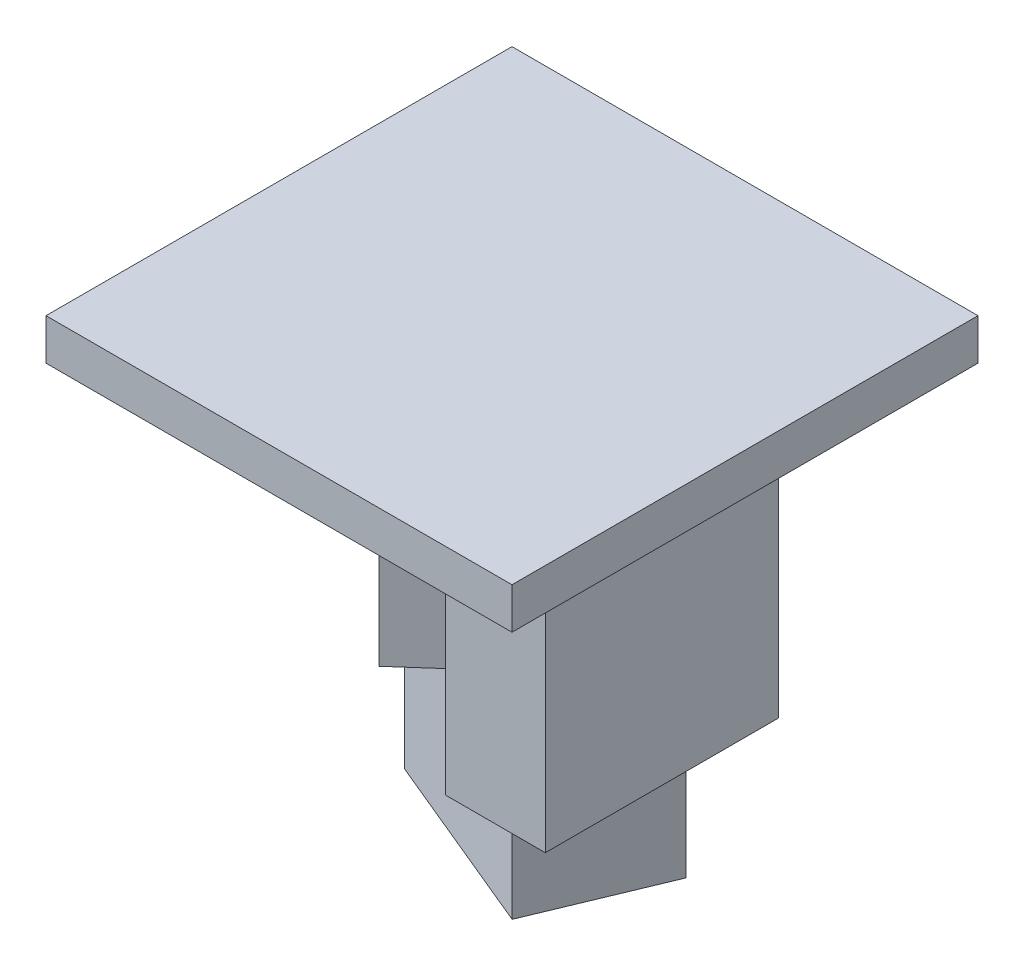
from build123d import *

# Parameters (mm, degrees)
SKETCH2_W           = 177.8
SKETCH2_H           = 177.8
BOSS_EXTRUDE2_DEPTH = 12.7
SKETCH2_2_W         = 177.8
SKETCH2_2_H         = 177.8
BOSS_EXTRUDE3_DEPTH = 3
SKETCH3_W           = 38.1
SKETCH3_H           = 88.9
BOSS_EXTRUDE4_DEPTH = 104.6
BOSS_EXTRUDE5_DEPTH = 53.8


with BuildPart() as part:
    # Sketch2 → Boss-Extrude2 (new body)
    with BuildSketch(Plane(origin=(0, 0, 0), x_dir=(1, 0, 0), z_dir=(0, 1, 0))):
        Rectangle(SKETCH2_W, SKETCH2_H)
    extrude(amount=BOSS_EXTRUDE2_DEPTH)

    # Sketch2_2 → Boss-Extrude3 (add)
    with BuildSketch(Plane(origin=(0, 0, 0), x_dir=(1, 0, 0), z_dir=(0, 1, 0))):
        Rectangle(SKETCH2_2_W, SKETCH2_2_H)
    extrude(amount=-BOSS_EXTRUDE3_DEPTH)

    # Sketch3 → Boss-Extrude4 (add)
    with BuildSketch(Plane.XZ.offset(3)):
        Polygon((-25.475339684, -50.8), (-63.5, -17.113723747), (-29.813723747, 20.91093657), (8.21093657, -12.775339684), align=None)
        with Locations((44.45, 6.35)):
            Rectangle(SKETCH3_W, SKETCH3_H)
    extrude(amount=BOSS_EXTRUDE4_DEPTH)

    # Sketch4 → Boss-Extrude5 (add)
    with BuildSketch(Plane.XZ.offset(107.6)):
        Polygon((-25.475339684, -50.8), (44.89207381, -21.561889285), (25.4, 25.349719711), (-44.967413494, -3.888391004), align=None)
    extrude(amount=BOSS_EXTRUDE5_DEPTH)


solid = part.part
